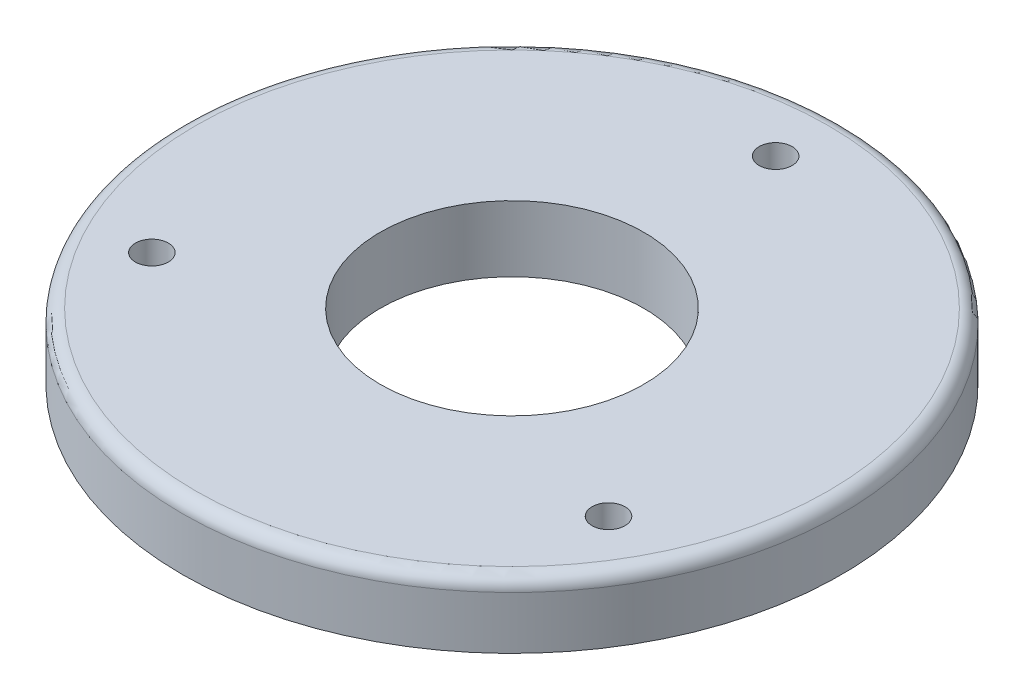
from build123d import *

# Parameters (mm, degrees)
SKETCH1_R           = 63.5
BOSS_EXTRUDE1_DEPTH = 12.7
SKETCH2_R           = 25.4
CUT_EXTRUDE1_DEPTH  = 13.7
SKETCH3_R           = 3.175
CUT_EXTRUDE2_DEPTH  = 13.7
FILLET1_R           = 2.54


with BuildPart() as part:
    # Sketch1 → Boss-Extrude1 (new body)
    with BuildSketch(Plane(origin=(0, 0, 0), x_dir=(1, 0, 0), z_dir=(0, 1, 0))):
        Circle(SKETCH1_R)
    extrude(amount=BOSS_EXTRUDE1_DEPTH)

    # Sketch2 → Cut-Extrude1 (cut, through all)
    with BuildSketch(Plane(origin=(0, 12.7, 0), x_dir=(1, 0, 0), z_dir=(0, 1, 0))):
        Circle(SKETCH2_R)
    extrude(amount=-CUT_EXTRUDE1_DEPTH, mode=Mode.SUBTRACT)

    # Sketch3 → Cut-Extrude2 (cut, through all)
    with BuildSketch(Plane(origin=(0, 12.7, 0), x_dir=(1, 0, 0), z_dir=(0, 1, 0))):
        with Locations((0, 50.8)):
            Circle(SKETCH3_R)
        with Locations((43.994090512, -25.4)):
            Circle(SKETCH3_R)
        with Locations((-43.994090512, -25.4)):
            Circle(SKETCH3_R)
    extrude(amount=-CUT_EXTRUDE2_DEPTH, mode=Mode.SUBTRACT)

    # Fillet1
    fillet1_edges = [part.edges().sort_by_distance(p)[0] for p in [
        (-63.5, 12.7, 0),
    ]]
    fillet(fillet1_edges, radius=FILLET1_R)


solid = part.part
